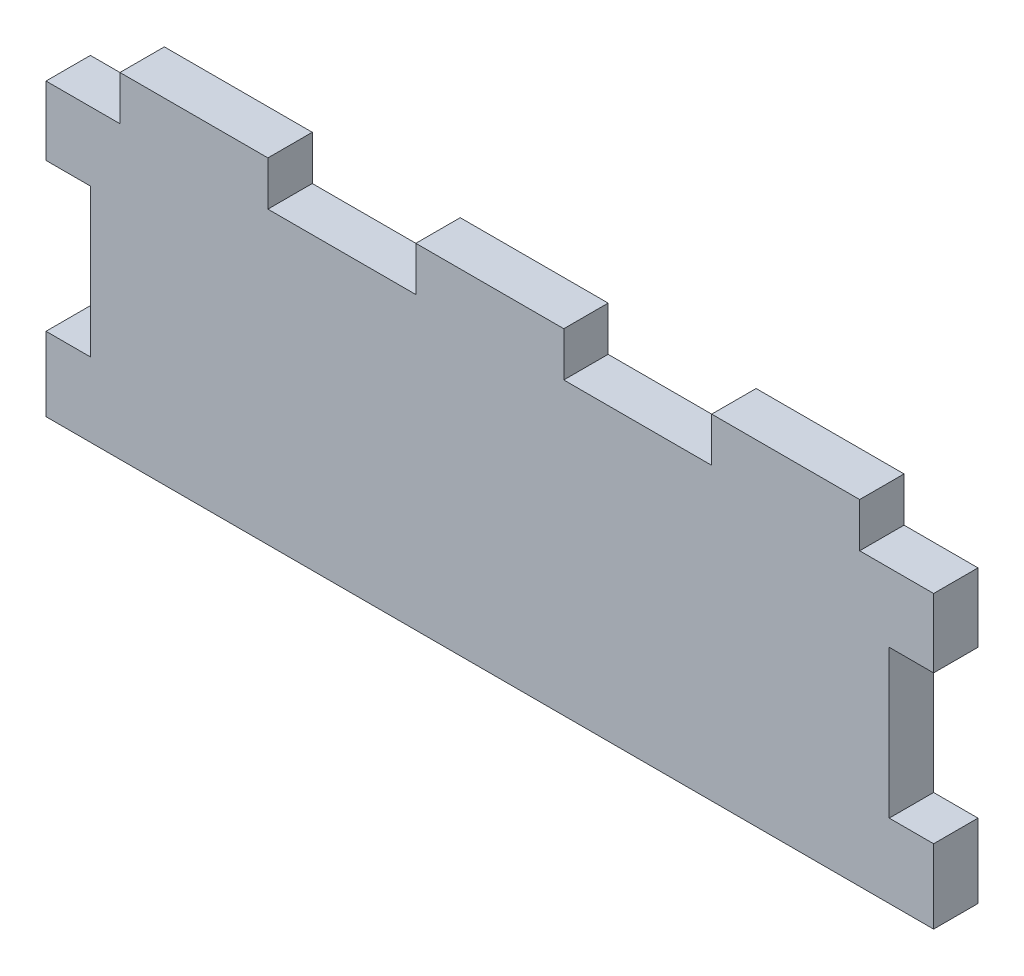
from build123d import *

# Parameters (mm, degrees)
SKETCH1_W           = 120
SKETCH1_H           = 45.3
BOSS_EXTRUDE1_DEPTH = 6
SKETCH2_W           = 10
SKETCH2_H           = 6
SKETCH2_W_2         = 20
SKETCH2_W_3         = 6
SKETCH2_H_2         = 20
CUT_EXTRUDE1_DEPTH  = 6


with BuildPart() as part:
    # Sketch1 → Boss-Extrude1 (new body)
    with BuildSketch(Plane.XY):
        with Locations((60, -22.65)):
            Rectangle(SKETCH1_W, SKETCH1_H)
    extrude(amount=BOSS_EXTRUDE1_DEPTH)

    # Sketch2 → Cut-Extrude1 (cut)
    with BuildSketch(Plane.XY.offset(6)):
        with Locations((5, -3)):
            Rectangle(SKETCH2_W, SKETCH2_H)
        with Locations((40, -3)):
            Rectangle(SKETCH2_W_2, SKETCH2_H)
        with Locations((80, -3)):
            Rectangle(SKETCH2_W_2, SKETCH2_H)
        with Locations((115, -3)):
            Rectangle(SKETCH2_W, SKETCH2_H)
        with Locations((117, -25.3)):
            Rectangle(SKETCH2_W_3, SKETCH2_H_2)
        with Locations((3, -25.3)):
            Rectangle(SKETCH2_W_3, SKETCH2_H_2)
    extrude(amount=-CUT_EXTRUDE1_DEPTH, mode=Mode.SUBTRACT)


solid = part.part
